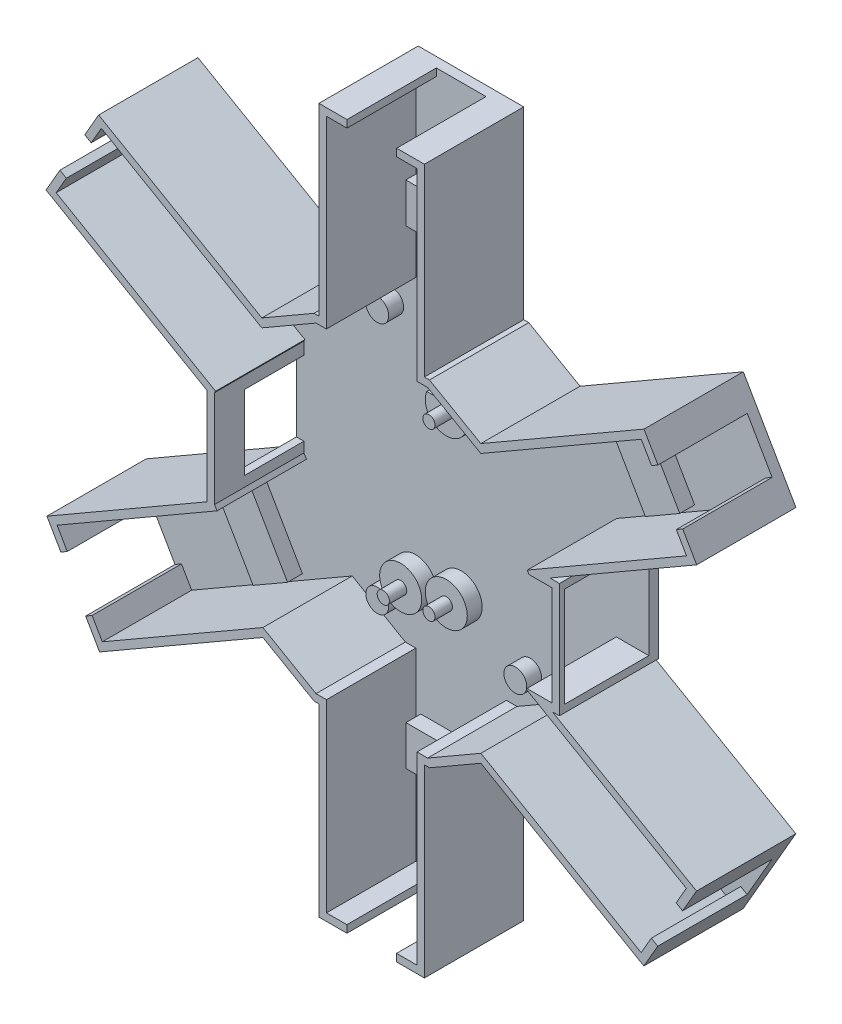
from build123d import *

# Parameters (mm, degrees)
AUFSATZ_LINEAR_AUSTRAGEN1_DEPTH = 18
AUFSATZ_LINEAR_AUSTRAGEN2_DEPTH = 2
SCHNITT_LINEAR_AUSTRAGEN1_REACH = 31.142
SCHNITT_LINEAR_AUSTRAGEN2_REACH = 35.939
SKIZZE5_W                       = 12
SKIZZE5_H                       = 15
SKIZZE7_R                       = 1.22999984
AUFSATZ_LINEAR_AUSTRAGEN3_DEPTH = 6.5
SKIZZE8_R                       = 4.22999984
SKIZZE8_R_2                     = 2.3
AUFSATZ_LINEAR_AUSTRAGEN4_DEPTH = 3
SKIZZE9_W                       = 16.252283896
SKIZZE9_H                       = 8
SKIZZE9_W_2                     = 16.225392475
AUFSATZ_LINEAR_AUSTRAGEN7_DEPTH = 3
SCHNITT_LINEAR_AUSTRAGEN3_REACH = 3.5
SKIZZE11_W                      = 10
SKIZZE11_H                      = 10
SCHNITT_LINEAR_AUSTRAGEN4_REACH = 24.734
SKIZZE13_W                      = 10
SKIZZE13_H                      = 10
SCHNITT_LINEAR_AUSTRAGEN5_REACH = 24.815
SKIZZE14_W                      = 10
SKIZZE14_H                      = 10
SCHNITT_LINEAR_AUSTRAGEN6_REACH = 3.5
SKIZZE15_W                      = 10
SKIZZE15_H                      = 10
SCHNITT_LINEAR_AUSTRAGEN7_REACH = 24.918
SKIZZE16_W                      = 10
SKIZZE16_H                      = 10
SCHNITT_LINEAR_AUSTRAGEN8_REACH = 24.774
SKIZZE17_W                      = 10
SKIZZE17_H                      = 10
SKIZZE18_W                      = 10
SKIZZE18_H                      = 1.5
SCHNITT_LINEAR_AUSTRAGEN9_DEPTH = 8


with BuildPart() as part:
    # Skizze1 → Aufsatz-Linear austragen1 (new body)
    with BuildSketch(Plane.XY):
        Polygon((-22.149859894, 27.765281808), (-11.635793215, 33.83000044), (-10.65000108, 33.83000044), (-10.65000108, 70.94999986), (10.5900012, 70.94999986), (10.5900012, 33.83000044), (11.612735063, 33.83000044), (21.946878227, 27.90320319), (54.822266278, 46.860690996), (65.431940836, 28.488460753), (35.875483821, 11.41999954), (37.79000014, 11.41999954), (37.79000014, -11.66999904), (36.372671479, -11.66999904), (65.402118422, -28.428154068), (54.791716349, -46.801638497), (21.961456264, -27.849347945), (11.636228403, -33.81000048), (10.608764603, -33.81000048), (10.588764643, -70.99999976), (-10.63000112, -70.99999976), (-10.63000112, -33.81000048), (-11.635211495, -33.81000048), (-21.94526311, -27.869445957), (-54.832668225, -46.841377939), (-65.441180026, -28.458395245), (-33.1799992, -9.82193495), (-33.1799992, 9.582671858), (-65.619428736, 28.349034811), (-55.023633975, 46.732102334), align=None)
        Polygon((-22.149950537, 26.033576659), (-11.234189479, 32.33000044), (-9.15000108, 32.33000044), (-9.15000108, 69.44999986), (9.0900012, 69.44999986), (9.0900012, 32.33000044), (11.2131258, 32.33000044), (21.948913697, 26.172853479), (54.272963006, 44.812413555), (63.382848908, 29.03729054), (31.311020441, 10.516235735), (31.653238716, 9.91999954), (36.29000014, 9.91999954), (36.29000014, -10.16999904), (31.252050971, -10.16999904), (31.132619329, -10.37701429), (63.352910716, -28.977183946), (54.242770108, -44.752743199), (21.961450411, -26.11734559), (11.234340849, -32.31000048), (9.109571053, -32.31000048), (9.089571093, -69.49999976), (-9.13000112, -69.49999976), (-9.13000112, -32.31000048), (-11.233987142, -32.31000048), (-21.945708018, -26.138007916), (-54.2831028, -44.792652518), (-63.392584266, -29.007267794), (-31.162137007, -10.388561496), (-31.6799992, -9.546253935), (-31.6799992, 9.963511331), (-31.471105622, 10.326986156), (-63.571974887, 28.897490395), (-54.473438465, 44.682904625), align=None, mode=Mode.SUBTRACT)
    extrude(amount=AUFSATZ_LINEAR_AUSTRAGEN1_DEPTH)

    # Skizze3 → Aufsatz-Linear austragen2 (add)
    with BuildSketch(Plane(origin=(0, 0, 0), x_dir=(-1, 0, 0), z_dir=(0, 0, -1))):
        Polygon((55.023633975, 46.732102334), (22.149859894, 27.765281808), (11.635793215, 33.83000044), (10.65000108, 33.83000044), (10.65000108, 70.94999986), (-10.5900012, 70.94999986), (-10.5900012, 33.83000044), (-11.612735063, 33.83000044), (-21.946878227, 27.90320319), (-54.822266278, 46.860690996), (-65.431940836, 28.488460753), (-35.875483821, 11.41999954), (-37.79000014, 11.41999954), (-37.79000014, -11.66999904), (-36.372671479, -11.66999904), (-65.402118422, -28.428154068), (-54.791716349, -46.801638497), (-21.961456264, -27.849347945), (-11.636228403, -33.81000048), (-10.608764603, -33.81000048), (-10.588764643, -70.99999976), (10.63000112, -70.99999976), (10.63000112, -33.81000048), (11.635211495, -33.81000048), (21.94526311, -27.869445957), (54.832668225, -46.841377939), (65.441180026, -28.458395245), (33.1799992, -9.82193495), (33.1799992, 9.582671858), (65.619428736, 28.349034811), align=None)
    extrude(amount=AUFSATZ_LINEAR_AUSTRAGEN2_DEPTH)

    # Skizze4 → Schnitt-Linear austragen1 (cut, up to next)
    with BuildSketch(Plane.ZY.offset(-36.29000014), mode=Mode.PRIVATE) as schnitt_linear_austragen1_sk1:
        Polygon((17.00382914, 9.91999954), (17.00382914, -10.16999904), (0.851260669, -10.16999904), (0, -10.16999904), (0, 9.91999954), (0.851260669, 9.91999954), align=None)
    schnitt_linear_austragen1_tool1 = extrude(schnitt_linear_austragen1_sk1.sketch, amount=-SCHNITT_LINEAR_AUSTRAGEN1_REACH, mode=Mode.PRIVATE) & part.part
    add(schnitt_linear_austragen1_tool1.solids().sort_by_distance((36.29, -0.125, 8.501915))[0], mode=Mode.SUBTRACT)

    # Skizze5 → Schnitt-Linear austragen2 (cut, up to next)
    with BuildSketch(Plane(origin=(-31.6799992, 0, 0), x_dir=(0, 0, -1), z_dir=(1, 0, 0)), mode=Mode.PRIVATE) as schnitt_linear_austragen2_sk1:
        with Locations((-6, 0)):
            Rectangle(SKIZZE5_W, SKIZZE5_H)
    schnitt_linear_austragen2_tool1 = extrude(schnitt_linear_austragen2_sk1.sketch, amount=-SCHNITT_LINEAR_AUSTRAGEN2_REACH, mode=Mode.PRIVATE) & part.part
    add(schnitt_linear_austragen2_tool1.solids().sort_by_distance((-31.679999, 0, 6))[0], mode=Mode.SUBTRACT)

    # Skizze7 → Aufsatz-Linear austragen3 (add)
    with BuildSketch(Plane.XY):
        with Locations((0, 15.00000048)):
            Circle(SKIZZE7_R)
        with Locations((0, -18.5000011)):
            Circle(SKIZZE7_R)
        with Locations((-9.1899994, -20.2700001)):
            Circle(SKIZZE7_R)
    extrude(amount=AUFSATZ_LINEAR_AUSTRAGEN3_DEPTH)

    # Skizze8 → Aufsatz-Linear austragen4 (add)
    with BuildSketch(Plane.XY):
        with Locations((-9.1899994, -20.2700001)):
            Circle(SKIZZE8_R)
        with Locations((0, -18.5000011)):
            Circle(SKIZZE8_R)
        with Locations((13.9, 25.897140228)):
            Circle(SKIZZE8_R_2)
        with Locations((-13.9, 25.897140228)):
            Circle(SKIZZE8_R_2)
        with Locations((13.9, -24.8615628)):
            Circle(SKIZZE8_R_2)
        with Locations((-13.9, -24.8615628)):
            Circle(SKIZZE8_R_2)
        with BuildLine():
            Line((3.936452455, 16.548303007), (-3.936452455, 16.548303007))
            ThreePointArc((-3.936452455, 16.548303007), (0, 10.77000064), (3.936452455, 16.548303007))
        make_face()
    extrude(amount=AUFSATZ_LINEAR_AUSTRAGEN4_DEPTH)

    # Skizze9 → Aufsatz-Linear austragen7 (add)
    with BuildSketch(Plane.XY):
        Polygon((-39.106966425, 34.662574989), (-47.255864546, 20.538698219), (-40.326487672, 16.540731718), (-32.177589551, 30.664608488), align=None)
        with Locations((-0.036140748, 47.33000044)):
            Rectangle(SKIZZE9_W, SKIZZE9_H)
        Polygon((40.096213315, 16.744336658), (31.986065924, 30.788205039), (38.913859811, 34.78891396), (47.024007202, 20.745045579), align=None)
        Polygon((40.10078632, -16.697308213), (47.029196881, -20.696949084), (38.916380603, -34.750441337), (31.987970041, -30.750800466), align=None)
        with Locations((-0.017304883, -47.31000048)):
            Rectangle(SKIZZE9_W_2, SKIZZE9_H)
        Polygon((-38.906027405, -34.762365837), (-31.978796823, -30.760681634), (-40.098111463, -16.705508406), (-47.025342045, -20.70719261), align=None)
    extrude(amount=AUFSATZ_LINEAR_AUSTRAGEN7_DEPTH)

    # Skizze11 → Schnitt-Linear austragen3 (cut, up to next)
    with BuildSketch(Plane.XZ.offset(-69.44999986), mode=Mode.PRIVATE) as schnitt_linear_austragen3_sk1:
        with Locations((0, 5)):
            Rectangle(SKIZZE11_W, SKIZZE11_H)
    schnitt_linear_austragen3_tool1 = extrude(schnitt_linear_austragen3_sk1.sketch, amount=-SCHNITT_LINEAR_AUSTRAGEN3_REACH, mode=Mode.PRIVATE) & part.part
    add(schnitt_linear_austragen3_tool1.solids().sort_by_distance((0, 69.45, 5))[0], mode=Mode.SUBTRACT)

    # Skizze13 → Schnitt-Linear austragen4 (cut, up to next)
    with BuildSketch(Plane(origin=(60.106593545, 34.710614216, 0), x_dir=(0, 0, 1), z_dir=(-0.86597514, -0.500087049, 0)), mode=Mode.PRIVATE) as schnitt_linear_austragen4_sk1:
        with Locations((5, 2.556930019)):
            Rectangle(SKIZZE13_W, SKIZZE13_H)
    schnitt_linear_austragen4_tool1 = extrude(schnitt_linear_austragen4_sk1.sketch, amount=-SCHNITT_LINEAR_AUSTRAGEN4_REACH, mode=Mode.PRIVATE) & part.part
    add(schnitt_linear_austragen4_tool1.solids().sort_by_distance((58.827906, 36.924852, 5))[0], mode=Mode.SUBTRACT)

    # Skizze14 → Schnitt-Linear austragen5 (cut, up to next)
    with BuildSketch(Plane(origin=(60.058107222, -34.682624727, 0), x_dir=(0, 0, 1), z_dir=(-0.865975074, 0.500087164, 0)), mode=Mode.PRIVATE) as schnitt_linear_austragen5_sk1:
        with Locations((5, -2.520094297)):
            Rectangle(SKIZZE14_W, SKIZZE14_H)
    schnitt_linear_austragen5_tool1 = extrude(schnitt_linear_austragen5_sk1.sketch, amount=-SCHNITT_LINEAR_AUSTRAGEN5_REACH, mode=Mode.PRIVATE) & part.part
    add(schnitt_linear_austragen5_tool1.solids().sort_by_distance((58.79784, -36.864964, 5))[0], mode=Mode.SUBTRACT)

    # Skizze15 → Schnitt-Linear austragen6 (cut, up to next)
    with BuildSketch(Plane(origin=(0, -69.49999976, 0), x_dir=(1, 0, 0), z_dir=(0, 1, 0)), mode=Mode.PRIVATE) as schnitt_linear_austragen6_sk1:
        with Locations((-0.020215013, -5)):
            Rectangle(SKIZZE15_W, SKIZZE15_H)
    schnitt_linear_austragen6_tool1 = extrude(schnitt_linear_austragen6_sk1.sketch, amount=-SCHNITT_LINEAR_AUSTRAGEN6_REACH, mode=Mode.PRIVATE) & part.part
    add(schnitt_linear_austragen6_tool1.solids().sort_by_distance((-0.020215, -69.5, 5))[0], mode=Mode.SUBTRACT)

    # Skizze16 → Schnitt-Linear austragen7 (cut, up to next)
    with BuildSketch(Plane(origin=(-60.113041463, -34.690230655, 0), x_dir=(0, 0, -1), z_dir=(0.866125522, 0.49982655, 0)), mode=Mode.PRIVATE) as schnitt_linear_austragen7_sk1:
        with Locations((-5, -2.551280899)):
            Rectangle(SKIZZE16_W, SKIZZE16_H)
    schnitt_linear_austragen7_tool1 = extrude(schnitt_linear_austragen7_sk1.sketch, amount=-SCHNITT_LINEAR_AUSTRAGEN7_REACH, mode=Mode.PRIVATE) & part.part
    add(schnitt_linear_austragen7_tool1.solids().sort_by_distance((-58.837844, -36.89996, 5))[0], mode=Mode.SUBTRACT)

    # Skizze17 → Schnitt-Linear austragen8 (cut, up to next)
    with BuildSketch(Plane(origin=(-60.221224503, 34.710841064, 0), x_dir=(0, 0, -1), z_dir=(0.866385869, -0.499375136, 0)), mode=Mode.PRIVATE) as schnitt_linear_austragen8_sk1:
        with Locations((-5, 2.400035044)):
            Rectangle(SKIZZE17_W, SKIZZE17_H)
    schnitt_linear_austragen8_tool1 = extrude(schnitt_linear_austragen8_sk1.sketch, amount=-SCHNITT_LINEAR_AUSTRAGEN8_REACH, mode=Mode.PRIVATE) & part.part
    add(schnitt_linear_austragen8_tool1.solids().sort_by_distance((-59.022707, 36.790198, 5))[0], mode=Mode.SUBTRACT)

    # Skizze18 → Schnitt-Linear austragen9 (cut)
    with BuildSketch(Plane(origin=(0, 0, 10), x_dir=(-1, 0, 0), z_dir=(0, 0, -1))):
        Polygon((-62.597238843, -33.285218949), (-57.596367204, -41.944969687), (-56.297404593, -41.194838941), (-61.298276232, -32.535088203), align=None)
        with Locations((0.020215013, -70.24999976)):
            Rectangle(SKIZZE18_W, SKIZZE18_H)
        Polygon((57.637899065, -41.980327591), (62.636164566, -33.319072372), (61.336976284, -32.569332546), (56.338710782, -41.230587766), align=None)
        Polygon((62.81916116, 33.207330871), (57.825409798, 41.871189557), (56.525830995, 41.122126853), (61.519582357, 32.458268167), align=None)
        with Locations((0, 70.19999986)):
            Rectangle(SKIZZE18_W, SKIZZE18_H)
        Polygon((-57.626433421, 42.004858322), (-62.627303913, 33.345106921), (-61.328341203, 32.594976347), (-56.327470711, 41.254727748), align=None)
    extrude(amount=-SCHNITT_LINEAR_AUSTRAGEN9_DEPTH, mode=Mode.SUBTRACT)


solid = part.part
